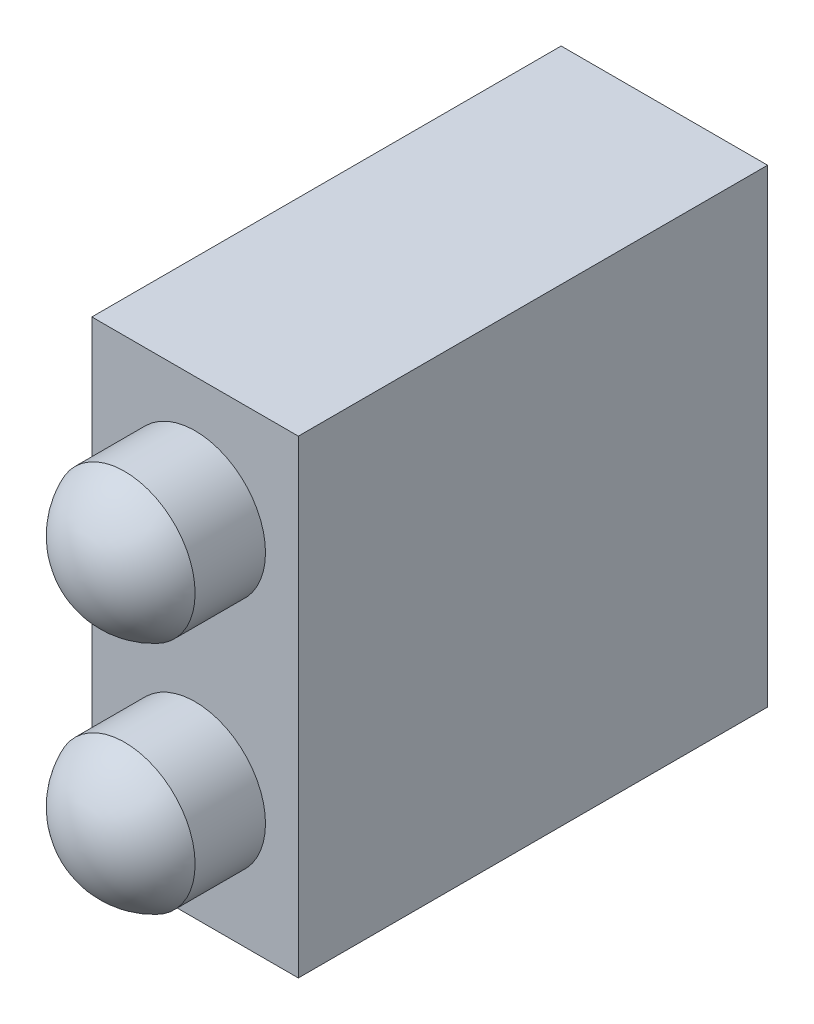
from build123d import *

# Parameters (mm, degrees)
SKETCH1_W                  = 4.4
SKETCH1_H                  = 10
BOSS_EXTRUDE1_DEPTH        = 10
SKETCH2_R                  = 1.5
BOSS_EXTRUDE2_DEPTH        = 1.5
DOME1_FACE_RADIUS          = 1.5
DOME1_HEIGHT               = 1
MIRROR1_COPY_1_FACE_RADIUS = 1.5
MIRROR1_COPY_1_HEIGHT      = 1


with BuildPart() as part:
    # Sketch1 → Boss-Extrude1 (new body)
    with BuildSketch(Plane.XY):
        Rectangle(SKETCH1_W, SKETCH1_H)
    extrude(amount=-BOSS_EXTRUDE1_DEPTH)

    # Sketch2 → Boss-Extrude2 (add)
    with BuildSketch(Plane.XY):
        with Locations((0, 2.5)):
            Circle(SKETCH2_R)
    boss_extrude2 = extrude(amount=BOSS_EXTRUDE2_DEPTH)

    # Dome1: a dome of height H over a round flat face of radius A is a cap of a sphere of radius (A * A + H * H) / (2 * H)
    dome1_r = (DOME1_FACE_RADIUS * DOME1_FACE_RADIUS + DOME1_HEIGHT * DOME1_HEIGHT) / (2 * DOME1_HEIGHT)
    dome1_base = Plane((0, 2.5, 1.5), z_dir=(0, 0, 1))
    with Locations(dome1_base.offset(DOME1_HEIGHT - dome1_r)):
        dome1_ball = Sphere(dome1_r, mode=Mode.PRIVATE)
    add(split(dome1_ball, bisect_by=dome1_base, keep=Keep.TOP, mode=Mode.PRIVATE))

    # Mirror1: Boss-Extrude2 across plane
    add(boss_extrude2.mirror(Plane.ZX))

    # Mirror1 copy 1: a dome of height H over a round flat face of radius A is a cap of a sphere of radius (A * A + H * H) / (2 * H)
    mirror1_copy_1_r = (MIRROR1_COPY_1_FACE_RADIUS * MIRROR1_COPY_1_FACE_RADIUS + MIRROR1_COPY_1_HEIGHT * MIRROR1_COPY_1_HEIGHT) / (2 * MIRROR1_COPY_1_HEIGHT)
    mirror1_copy_1_base = Plane((0, -2.5, 1.5), z_dir=(0, 0, 1))
    with Locations(mirror1_copy_1_base.offset(MIRROR1_COPY_1_HEIGHT - mirror1_copy_1_r)):
        mirror1_copy_1_ball = Sphere(mirror1_copy_1_r, mode=Mode.PRIVATE)
    add(split(mirror1_copy_1_ball, bisect_by=mirror1_copy_1_base, keep=Keep.TOP, mode=Mode.PRIVATE))


solid = part.part
